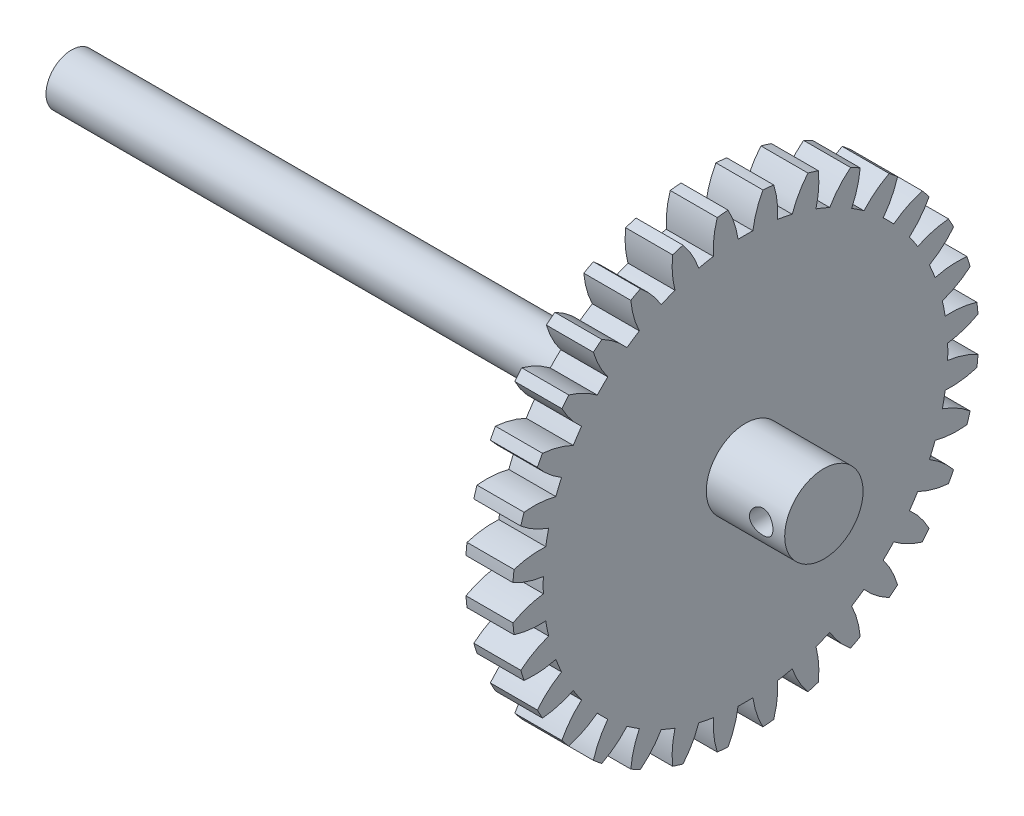
from build123d import *

# Parameters (mm, degrees)
BASPROSKE_W             = 6
BASPROSKE_H             = 29.75
TOOTHCUT_DEPTH          = 43.498529386
TEETHCUTS_COUNT         = 32
TEETHCUTS_ANGLE         = 348.75
BORSKE_R                = 0.4
BORE_DEPTH              = 50.0000508
SKETCH1_R               = 5
BOSS_EXTRUDE1_DEPTH     = 10
SKETCH2_R               = 3.25
BOSS_EXTRUDE2_DEPTH     = 80
SKETCH3_R               = 1.5
CUT_EXTRUDE1_DEPTH      = 91.33401589
CUT_EXTRUDE1_DEPTH_BACK = 91.33401589
SKETCH4_R               = 1.725
CUT_EXTRUDE2_DEPTH      = 2.5


with BuildPart() as part:
    # BasProSke → Base-Revolve (revolve)
    with BuildSketch(Plane(origin=(0, 0, 0), x_dir=(1, 0, 0), z_dir=(0, 1, 0)), mode=Mode.PRIVATE) as base_revolve_sk:
        with Locations((3, 14.875)):
            Rectangle(BASPROSKE_W, BASPROSKE_H)
    revolve(base_revolve_sk.sketch.rotate(Axis((-10, 0, 0), (1, 0, 0)), 180), axis=Axis((-10, 0, 0), (1, 0, 0)))

    # TooCutSke → ToothCut (cut, through all)
    with BuildSketch(Plane(origin=(0, 0, 0), x_dir=(0, 0, -1), z_dir=(1, 0, 0))):
        with BuildLine():
            ThreePointArc((0.948063121, 25.794082821), (0, 25.8115), (-0.948063121, 25.794082821))
            ThreePointArc((-0.948063121, 25.794082821), (-1.412588604, 27.80222237), (-2.237243361, 29.691230815))
            ThreePointArc((-2.237243361, 29.691230815), (0, 29.7754), (2.237243361, 29.691230815))
            ThreePointArc((2.237243361, 29.691230815), (1.412588604, 27.80222237), (0.948063121, 25.794082821))
        make_face()
    toothcut = extrude(amount=TOOTHCUT_DEPTH, mode=Mode.SUBTRACT)

    # TeethCuts: ToothCut ×32 about axis
    teethcuts_axis = Axis((-10, 0, 0), (1, 0, 0))
    for i in range(1, TEETHCUTS_COUNT):
        add(toothcut.rotate(teethcuts_axis, i * TEETHCUTS_ANGLE / (TEETHCUTS_COUNT - 1)), mode=Mode.SUBTRACT)

    # BorSke → Bore (cut, symmetric)
    with BuildSketch(Plane(origin=(0, 0, 0), x_dir=(0, 0, -1), z_dir=(1, 0, 0))):
        with Locations(Location((0, 0, 0), (0, 0, 180))):
            Circle(BORSKE_R)
    extrude(amount=BORE_DEPTH, both=True, mode=Mode.SUBTRACT)

    # Sketch1 → Boss-Extrude1 (add)
    with BuildSketch(Plane(origin=(6, 0, 0), x_dir=(0, 0, -1), z_dir=(1, 0, 0))):
        with Locations(Location((0, 0, 0), (0, 0, 180))):
            Circle(SKETCH1_R)
    extrude(amount=BOSS_EXTRUDE1_DEPTH)

    # Sketch2 → Boss-Extrude2 (add)
    with BuildSketch(Plane.ZY):
        with Locations(Location((0, 0, 0), (0, 0, 180))):
            Circle(SKETCH2_R)
    extrude(amount=BOSS_EXTRUDE2_DEPTH)

    # Sketch3 → Cut-Extrude1 (cut, two sides)
    with BuildSketch(Plane.XY) as cut_extrude1_sk:
        with Locations((13, 0)):
            Circle(SKETCH3_R)
    extrude(amount=CUT_EXTRUDE1_DEPTH, mode=Mode.SUBTRACT)
    extrude(cut_extrude1_sk.sketch, amount=-CUT_EXTRUDE1_DEPTH_BACK, mode=Mode.SUBTRACT)

    # Sketch4 → Cut-Extrude2 (cut)
    with BuildSketch(Plane.ZY):
        with Locations((-23.382519588, -6.97264496)):
            Circle(SKETCH4_R)
    extrude(amount=-CUT_EXTRUDE2_DEPTH, mode=Mode.SUBTRACT)


solid = part.part
